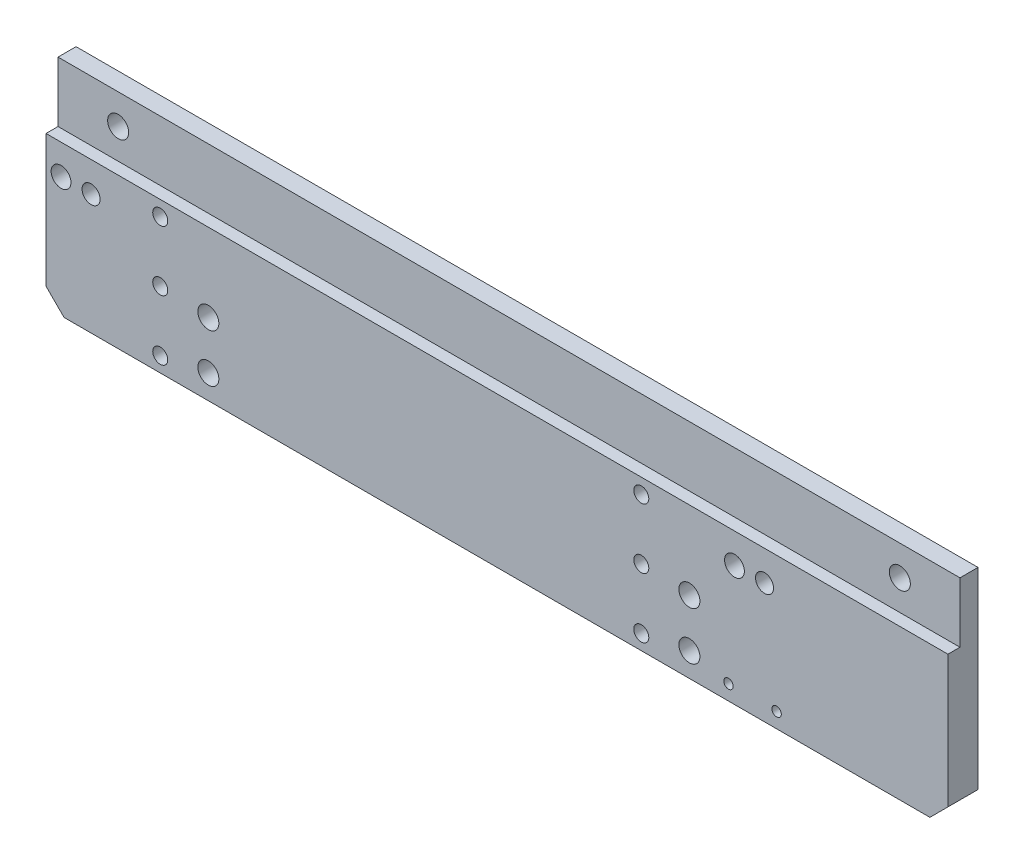
from build123d import *

# Parameters (mm, degrees)
BOSS_EXTRUDE1_DEPTH  = 5
SKETCH2_W            = 2
SKETCH2_H            = 10
CUT_EXTRUDE1_DEPTH   = 151
SKETCH3_R            = 1.75
SKETCH3_R_2          = 1.5
SKETCH3_R_3          = 1.65
SKETCH3_R_4          = 0.785
CUT_EXTRUDE2_DEPTH   = 6
SKETCH4_R            = 2
CUT_EXTRUDE3_DEPTH   = 2.5
SKETCH5_R            = 1.25
CUT_EXTRUDE4_DEPTH   = 3.5
LPATTERN1_COUNT      = 3
LPATTERN1_PITCH      = 10
LPATTERN1_COUNT_DIR2 = 2
LPATTERN1_PITCH_DIR2 = 80


with BuildPart() as part:
    # Sketch1 → Boss-Extrude1 (new body)
    with BuildSketch(Plane.XY):
        Polygon((72, -17.5), (75, -14.5), (75, 17.5), (-75, 17.5), (-75, -14.5), (-72, -17.5), align=None)
    extrude(amount=BOSS_EXTRUDE1_DEPTH)

    # Sketch2 → Cut-Extrude1 (cut, through all)
    with BuildSketch(Plane(origin=(75, 0, 0), x_dir=(0, 0, -1), z_dir=(1, 0, 0))):
        with Locations((-4, 12.5)):
            Rectangle(SKETCH2_W, SKETCH2_H)
    extrude(amount=-CUT_EXTRUDE1_DEPTH, mode=Mode.SUBTRACT)

    # Sketch3 → Cut-Extrude2 (cut, through all)
    with BuildSketch(Plane(origin=(0, 0, 0), x_dir=(-1, 0, 0), z_dir=(0, 0, -1))):
        with Locations((-65, 12.5)):
            Circle(SKETCH3_R)
        with Locations((65, 12.5)):
            Circle(SKETCH3_R)
        with Locations((-44.5, 2.5)):
            Circle(SKETCH3_R_2)
        with Locations((-39.5, 2.5)):
            Circle(SKETCH3_R_3)
        with Locations((-46.5, -15)):
            Circle(SKETCH3_R_4)
        with Locations((-38.5, -15)):
            Circle(SKETCH3_R_4)
        with Locations((-32, -5.5)):
            Circle(SKETCH3_R)
        with Locations((-32, -13.5)):
            Circle(SKETCH3_R)
        with Locations((48, -5.5)):
            Circle(SKETCH3_R)
        with Locations((48, -13.5)):
            Circle(SKETCH3_R)
        with Locations((67.5, 2.5)):
            Circle(SKETCH3_R_2)
        with Locations((72.5, 2.5)):
            Circle(SKETCH3_R_3)
    extrude(amount=-CUT_EXTRUDE2_DEPTH, mode=Mode.SUBTRACT)

    # Sketch4 → Cut-Extrude3 (cut)
    with BuildSketch(Plane(origin=(0, 0, 0), x_dir=(-1, 0, 0), z_dir=(0, 0, -1))):
        with Locations((-24, 5)):
            Circle(SKETCH4_R)
    cut_extrude3 = extrude(amount=-CUT_EXTRUDE3_DEPTH, mode=Mode.SUBTRACT)

    # Sketch5 → Cut-Extrude4 (cut, through all)
    with BuildSketch(Plane(origin=(0, 0, 2.5), x_dir=(-1, 0, 0), z_dir=(0, 0, -1))):
        with Locations((-24, 5)):
            Circle(SKETCH5_R)
    cut_extrude4 = extrude(amount=-CUT_EXTRUDE4_DEPTH, mode=Mode.SUBTRACT)

    # LPattern1: Cut-Extrude3, Cut-Extrude4 3 × 2
    with Locations(*[(-j * LPATTERN1_PITCH_DIR2, -i * LPATTERN1_PITCH, 0) for i in range(LPATTERN1_COUNT) for j in range(LPATTERN1_COUNT_DIR2) if (i, j) != (0, 0)]):
        add(cut_extrude3, mode=Mode.SUBTRACT)
        add(cut_extrude4, mode=Mode.SUBTRACT)


solid = part.part
